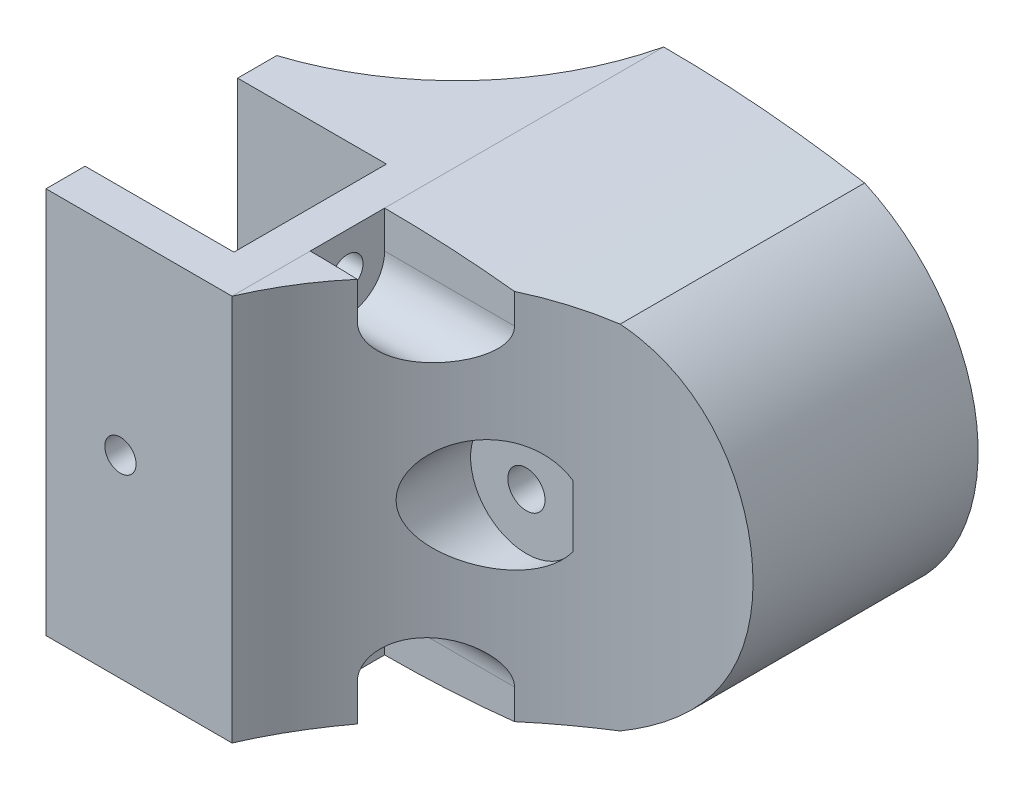
from build123d import *

# Parameters (mm, degrees)
SKETCH_1_W              = 52
SKETCH_1_H              = 52
EXTRUDE_1_DEPTH         = 31
SKETCH_2_W              = 20.5
SKETCH_2_H              = 52
CUT_EXTRUDE_1_DEPTH     = 20
SKETCH_5_R              = 26
EXTRUDE_2_DEPTH         = 31
CUT_EXTRUDE_2_DEPTH     = 32
SKETCH_7_W              = 20
SKETCH_7_H              = 20.5
CUT_EXTRUDE_3_DEPTH     = 53
EXTRUDE_3_DEPTH         = 27
SKETCH_10_W             = 19
SKETCH_10_H             = 14
SKETCH_11_W             = 19
SKETCH_11_H             = 28
CUT_EXTRUDE_4_DEPTH     = 27
EXTRUDE_4_DEPTH         = 52
SKETCH_13_R             = 2.1
CUT_EXTRUDE_5_DEPTH     = 59
SKETCH_14_R             = 2.1
CUT_EXTRUDE_6_DEPTH     = 48.25
SKETCH_15_R             = 5
CUT_EXTRUDE_7_DEPTH     = 43.2500001
SKETCH_17_W             = 10
SKETCH_17_H             = 42.25
CUT_EXTRUDE_8_DEPTH     = 6.0000001
SKETCH_18_R             = 5
CUT_EXTRUDE_9_DEPTH     = 28.0000001
SKETCH_19_R             = 2.5
CUT_EXTRUDE_10_DEPTH    = 59.0000001
CUT_EXTRUDE1_DEPTH      = 53.0000001
SKETCH3_R               = 7.5
CUT_EXTRUDE2_DEPTH      = 22.300523217
CUT_EXTRUDE2_DEPTH_BACK = 2
CUT_EXTRUDE_11_DEPTH    = 28.0000001
SKETCH_21_W             = 15
SKETCH_21_H             = 9.144379334
EXTRUDE_5_DEPTH         = 21
CUT_EXTRUDE_12_DEPTH    = 15
FILLET_1_R              = 3


with BuildPart() as part:
    # Эскиз1 → Бобышка-Вытянуть1 (new body)
    with BuildSketch(Plane.XY):
        with Locations((26, 0)):
            Rectangle(SKETCH_1_W, SKETCH_1_H)
    extrude(amount=EXTRUDE_1_DEPTH)

    # Эскиз2 → Вырез-Вытянуть1 (cut)
    with BuildSketch(Plane.ZY):
        with Locations((15.5, 0)):
            Rectangle(SKETCH_2_W, SKETCH_2_H)
    extrude(amount=-CUT_EXTRUDE_1_DEPTH, mode=Mode.SUBTRACT)

    # Эскиз5 → Бобышка-Вытянуть2 (add)
    with BuildSketch(Plane.XY.offset(31)):
        with Locations((41.25, 0)):
            Circle(SKETCH_5_R)
    extrude(amount=-EXTRUDE_2_DEPTH)

    # Эскиз6 → Вырез-Вытянуть2 (cut, through all)
    with BuildSketch(Plane.XY.offset(31)):
        with BuildLine():
            Line((52, 23.673561202), (52, 26))
            Line((52, 26), (25, 26))
            ThreePointArc((25, 26), (38.550021379, 25.417314778), (52, 23.673561202))
        make_face()
    cut_extrude_2 = extrude(amount=-CUT_EXTRUDE_2_DEPTH, mode=Mode.SUBTRACT)

    # Зеркальное отражение1: Вырез-Вытянуть2 across plane
    add(cut_extrude_2.mirror(Plane(origin=(0, 0, 0), x_dir=(0, 0, 1), z_dir=(0, -1, 0))), mode=Mode.SUBTRACT)

    # Эскиз7 → Вырез-Вытянуть3 (cut, through all)
    with BuildSketch(Plane(origin=(0, 26, 0), x_dir=(1, 0, 0), z_dir=(0, 1, 0))):
        with Locations((10, -15.5)):
            Rectangle(SKETCH_7_W, SKETCH_7_H)
    extrude(amount=-CUT_EXTRUDE_3_DEPTH, mode=Mode.SUBTRACT)

    # Эскиз9 → Бобышка-Вытянуть3 (add)
    with BuildSketch(Plane(origin=(0, 0, 0), x_dir=(-1, 0, 0), z_dir=(0, 0, -1))):
        with BuildLine():
            Line((-25, 26), (-25, -26))
            ThreePointArc((-25, -26), (-38.550021379, -25.417314778), (-52, -23.673561202))
            ThreePointArc((-52, -23.673561202), (-67.25, 0), (-52, 23.673561202))
            ThreePointArc((-52, 23.673561202), (-38.550021379, 25.417314778), (-25, 26))
        make_face()
    extrude(amount=EXTRUDE_3_DEPTH)

    # Эскиз10 → Вырез-Повернуть2 (revolve, cut)
    with BuildSketch(Plane.ZY.offset(-41.25)):
        with Locations((-11.25, 7)):
            Rectangle(SKETCH_10_W, SKETCH_10_H)
    revolve(axis=Axis((41.25, 0, -20.75), (0, 0, 1)), mode=Mode.SUBTRACT)

    # Эскиз11 → Вырез-Вытянуть4 (cut, through all)
    with BuildSketch(Plane(origin=(0, 0, 0), x_dir=(0, 0, -1), z_dir=(0, -1, 0))):
        with Locations((11.25, 41.25)):
            Rectangle(SKETCH_11_W, SKETCH_11_H)
    extrude(amount=CUT_EXTRUDE_4_DEPTH, mode=Mode.SUBTRACT)

    # Эскиз12 → Бобышка-Вытянуть4 (add)
    with BuildSketch(Plane.XZ.offset(26)):
        with BuildLine():
            Line((0, 0), (25, 0))
            Line((25, 0), (25, -27))
            ThreePointArc((25, -27), (16.039335617, -10.222837391), (0, 0))
        make_face()
    extrude(amount=-EXTRUDE_4_DEPTH)

    # Эскиз13 → Вырез-Вытянуть5 (cut, through all)
    with BuildSketch(Plane.XY.offset(31)):
        with Locations((10, 0)):
            Circle(SKETCH_13_R)
    extrude(amount=-CUT_EXTRUDE_5_DEPTH, mode=Mode.SUBTRACT)

    # Эскиз14 → Вырез-Вытянуть6 (cut, through all)
    with BuildSketch(Plane.ZY.offset(-20)):
        with Locations((15.5, -21)):
            Circle(SKETCH_14_R)
        with Locations((15.5, 21)):
            Circle(SKETCH_14_R)
    extrude(amount=-CUT_EXTRUDE_6_DEPTH, mode=Mode.SUBTRACT)

    # Эскиз15 → Вырез-Вытянуть7 (cut, through all)
    with BuildSketch(Plane(origin=(25, 0, 0), x_dir=(0, 0, -1), z_dir=(1, 0, 0))):
        with Locations((-15.5, 21)):
            Circle(SKETCH_15_R)
        with Locations((-15.5, -21)):
            Circle(SKETCH_15_R)
    extrude(amount=CUT_EXTRUDE_7_DEPTH, mode=Mode.SUBTRACT)

    # Эскиз17 → Вырез-Вытянуть8 (cut, through all)
    with BuildSketch(Plane(origin=(0, 21, 0), x_dir=(0, 0, -1), z_dir=(0, 1, 0))):
        with Locations((-15.5, -46.125)):
            Rectangle(SKETCH_17_W, SKETCH_17_H)
    cut_extrude_8 = extrude(amount=CUT_EXTRUDE_8_DEPTH, mode=Mode.SUBTRACT)

    # Зеркальное отражение2: Вырез-Вытянуть8 across plane
    add(cut_extrude_8.mirror(Plane(origin=(0, 0, 0), x_dir=(0, 0, 1), z_dir=(0, -1, 0))), mode=Mode.SUBTRACT)

    # Эскиз18 → Вырез-Вытянуть9 (cut, through all)
    with BuildSketch(Plane(origin=(0, 0, 0), x_dir=(-1, 0, 0), z_dir=(0, 0, -1))):
        with Locations((-10, 0)):
            Circle(SKETCH_18_R)
    extrude(amount=CUT_EXTRUDE_9_DEPTH, mode=Mode.SUBTRACT)

    # Эскиз19 → Вырез-Вытянуть10 (cut, through all)
    with BuildSketch(Plane.XY.offset(31)):
        with Locations((41.25, 0)):
            Circle(SKETCH_19_R)
    extrude(amount=-CUT_EXTRUDE_10_DEPTH, mode=Mode.SUBTRACT)

    # Sketch1 → Cut-Extrude1 (cut, through all)
    with BuildSketch(Plane(origin=(0, 26, 0), x_dir=(1, 0, 0), z_dir=(0, 1, 0))):
        with BuildLine():
            Line((25, -31), (67.25, -31))
            Line((67.25, -31), (67.25, -3.25))
            ThreePointArc((67.25, -3.25), (41.975877859, -10.807868092), (25, -31))
        make_face()
    extrude(amount=-CUT_EXTRUDE1_DEPTH, mode=Mode.SUBTRACT)

    # Sketch3 → Cut-Extrude2 (cut, two sides)
    with BuildSketch(Plane.XY.offset(9.699476883)) as cut_extrude2_sk:
        with Locations((41.25, 0)):
            Circle(SKETCH3_R)
    extrude(amount=CUT_EXTRUDE2_DEPTH, mode=Mode.SUBTRACT)
    extrude(cut_extrude2_sk.sketch, amount=-CUT_EXTRUDE2_DEPTH_BACK, mode=Mode.SUBTRACT)

    # Эскиз20 → Вырез-Вытянуть11 (cut, through all)
    with BuildSketch(Plane(origin=(0, 0, 0), x_dir=(-1, 0, 0), z_dir=(0, 0, -1))):
        with BuildLine():
            Line((-10, 5), (0, 5))
            Line((0, 5), (0, -5))
            Line((0, -5), (-15, -5))
            Line((-15, -5), (-15, 0))
            ThreePointArc((-15, 0), (-13.535533906, 3.535533906), (-10, 5))
        make_face()
    extrude(amount=CUT_EXTRUDE_11_DEPTH, mode=Mode.SUBTRACT)

    # Эскиз21 → Бобышка-Вытянуть5 (add)
    with BuildSketch(Plane(origin=(0, -5, 0), x_dir=(1, 0, 0), z_dir=(0, 1, 0))):
        with Locations((7.5, 4.572189667)):
            Rectangle(SKETCH_21_W, SKETCH_21_H)
    extrude(amount=-EXTRUDE_5_DEPTH)

    # Эскиз22 → Вырез-Вытянуть12 (cut)
    with BuildSketch(Plane.XZ.offset(26)):
        Polygon((10, 1.925426481), (7.25, 0.33771324), (7.25, -2.83771324), (10, -4.425426481), (12.75, -2.83771324), (12.75, 0.33771324), align=None)
    extrude(amount=-CUT_EXTRUDE_12_DEPTH, mode=Mode.SUBTRACT)

    # Скругление1
    fillet_1_edges = [part.edges().sort_by_distance(p)[0] for p in [
        (0, -15.5, -9.144379334),
    ]]
    fillet(fillet_1_edges, radius=FILLET_1_R)


solid = part.part
